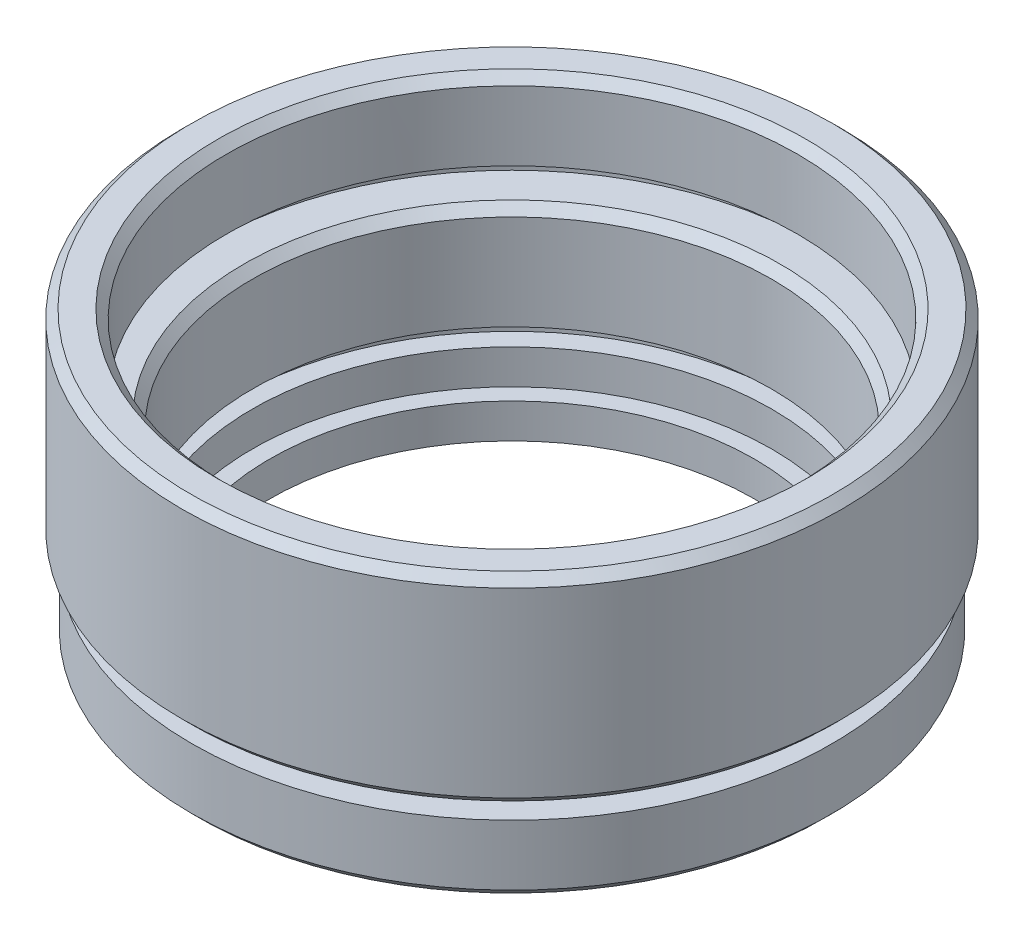
from build123d import *

# Parameters (mm, degrees)
CHAMFER_1_SIZE = 0.5


with BuildPart() as part:
    # 草图1 → 旋转1 (revolve)
    with BuildSketch(Plane.XY, mode=Mode.PRIVATE) as revolve_1_sk:
        Polygon((14, 0), (14, 2), (15, 2), (15, 4), (16.1, 4), (16.1, 5), (15, 5), (15, 11), (17.6, 11), (17.6, 12), (16.5, 12), (16.5, 16.5), (18.55, 16.5), (19.05, 16), (19.05, 5.5), (18.55, 5), (17, 5), (17, 4), (18.5, 4), (18.5, 0.5), (18, 0), align=None)
    revolve(revolve_1_sk.sketch.rotate(Axis((0, 0, 0), (0, 1, 0)), 90), axis=Axis((0, 0, 0), (0, 1, 0)))  # turned: the seam where the file's is

    # 倒角1
    chamfer_1_edges = [part.edges().sort_by_distance(p)[0] for p in [
        (0, 11, 15),
        (0, 16.5, 16.5),
    ]]
    chamfer(chamfer_1_edges, length=CHAMFER_1_SIZE)


solid = part.part
